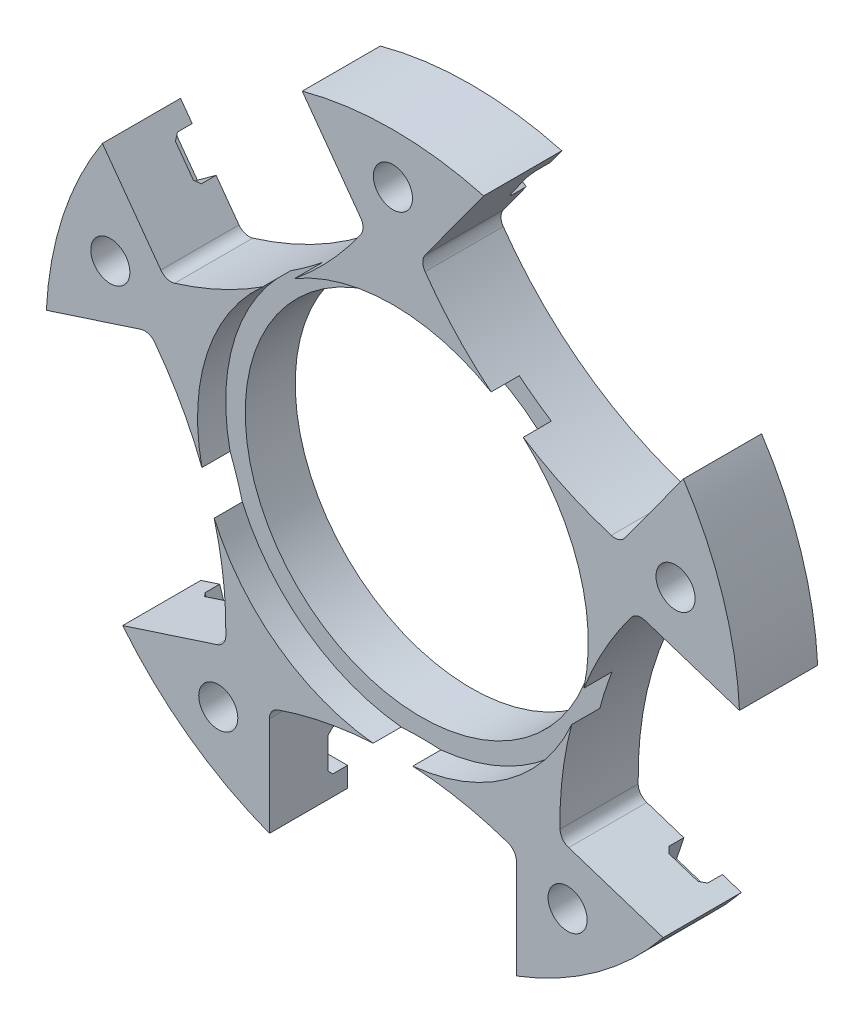
from build123d import *

# Parameters (mm, degrees)
SKETCH1_R                = 28.194
SKETCH1_R_2              = 14.2875
BOSS_EXTRUDE1_DEPTH      = 6.35
SKETCH1_3_R              = 15.875
SKETCH1_3_R_2            = 14.2875
CUT_EXTRUDE1_DEPTH       = 2.286
CUT_EXTRUDE5_DEPTH       = 41.374816062
CIRPATTERN1_COUNT        = 5
CUT_EXTRUDE6_DEPTH       = 1.8796
CIRPATTERN2_COUNT        = 5
CIRPATTERN2_COPY_1_DEPTH = 1.8796
CIRPATTERN2_COPY_2_DEPTH = 1.8796
CIRPATTERN2_COPY_3_DEPTH = 1.8796
CIRPATTERN2_COPY_4_DEPTH = 1.8796
SKETCH4_R                = 1.5875
CUT_EXTRUDE7_DEPTH       = 41.350542006
CIRPATTERN3_COUNT        = 5


with BuildPart() as part:
    # Sketch1 → Boss-Extrude1 (new body)
    with BuildSketch(Plane.XY):
        Circle(SKETCH1_R)
        Circle(SKETCH1_R_2, mode=Mode.SUBTRACT)
    extrude(amount=-BOSS_EXTRUDE1_DEPTH)

    # Sketch1_3 → Cut-Extrude1 (cut)
    with BuildSketch(Plane.XY):
        Circle(SKETCH1_3_R)
        Circle(SKETCH1_3_R_2, mode=Mode.SUBTRACT)
    extrude(amount=-CUT_EXTRUDE1_DEPTH, mode=Mode.SUBTRACT)

    # Sketch2 → Cut-Extrude5 (cut, through all)
    with BuildSketch(Plane.XY):
        with BuildLine():
            Line((-10.033, -28.194), (10.033, -28.194))
            Line((10.033, -28.194), (10.033, -18.273516145))
            ThreePointArc((10.033, -18.273516145), (9.84417878, -17.683574397), (9.347899083, -17.312911233))
            ThreePointArc((9.347899083, -17.312911233), (0, -15.748), (-9.347899083, -17.312911233))
            ThreePointArc((-9.347899083, -17.312911233), (-9.84417878, -17.683574397), (-10.033, -18.273516145))
            Line((-10.033, -18.273516145), (-10.033, -28.194))
        make_face()
    cut_extrude5 = extrude(amount=-CUT_EXTRUDE5_DEPTH, mode=Mode.SUBTRACT)

    # CirPattern1: Cut-Extrude5 ×5 about axis
    cirpattern1_axis = Axis((0, 0, 0), (0, 0, 1))
    for i in range(1, CIRPATTERN1_COUNT):
        add(cut_extrude5.rotate(cirpattern1_axis, i * 360 / CIRPATTERN1_COUNT), mode=Mode.SUBTRACT)

    # Sketch3 → Cut-Extrude6 (cut)
    with BuildSketch(Plane(origin=(-10.033, 0, 0), x_dir=(0, 0, -1), z_dir=(1, 0, 0))):
        Polygon((6.35, -21.433544869), (5.15112, -21.433544869), (4.7498, -21.834864869), (4.7498, -24.334224869), (5.15112, -24.735544869), (6.35, -24.735544869), align=None)
    cut_extrude6 = extrude(amount=-CUT_EXTRUDE6_DEPTH, mode=Mode.SUBTRACT)

    # Mirror1: Cut-Extrude6 across plane
    add(cut_extrude6.mirror(Plane(origin=(0, 0, 0), x_dir=(0, 0, 1), z_dir=(1, 0, 0))), mode=Mode.SUBTRACT)

    # CirPattern2: Cut-Extrude6 ×5 about axis
    cirpattern2_axis = Axis((0, 0, -6.35), (0, 0, 1))
    for i in range(1, CIRPATTERN2_COUNT):
        add(cut_extrude6.rotate(cirpattern2_axis, i * 360 / CIRPATTERN2_COUNT), mode=Mode.SUBTRACT)

    # CirPattern2 copy 1 sketch → CirPattern2 copy 1 (cut)
    with BuildSketch(Plane(origin=(3.100367505, 9.541950028, 0), x_dir=(0, 0, -1), z_dir=(-0.3090169943749473, -0.9510565162951535, 0))):
        Polygon((6.35, 21.433544869), (5.15112, 21.433544869), (4.7498, 21.834864869), (4.7498, 24.334224869), (5.15112, 24.735544869), (6.35, 24.735544869), align=None)
    extrude(amount=-CIRPATTERN2_COPY_1_DEPTH, mode=Mode.SUBTRACT)

    # CirPattern2 copy 2 sketch → CirPattern2 copy 2 (cut)
    with BuildSketch(Plane(origin=(-8.116867505, 5.897249436, 0), x_dir=(0, 0, -1), z_dir=(0.8090169943749475, -0.5877852522924731, 0))):
        Polygon((6.35, 21.433544869), (5.15112, 21.433544869), (4.7498, 21.834864869), (4.7498, 24.334224869), (5.15112, 24.735544869), (6.35, 24.735544869), align=None)
    extrude(amount=-CIRPATTERN2_COPY_2_DEPTH, mode=Mode.SUBTRACT)

    # CirPattern2 copy 3 sketch → CirPattern2 copy 3 (cut)
    with BuildSketch(Plane(origin=(-8.116867505, -5.897249436, 0), x_dir=(0, 0, -1), z_dir=(0.8090169943749475, 0.5877852522924731, 0))):
        Polygon((6.35, 21.433544869), (5.15112, 21.433544869), (4.7498, 21.834864869), (4.7498, 24.334224869), (5.15112, 24.735544869), (6.35, 24.735544869), align=None)
    extrude(amount=-CIRPATTERN2_COPY_3_DEPTH, mode=Mode.SUBTRACT)

    # CirPattern2 copy 4 sketch → CirPattern2 copy 4 (cut)
    with BuildSketch(Plane(origin=(3.100367505, -9.541950028, 0), x_dir=(0, 0, -1), z_dir=(-0.3090169943749474, 0.9510565162951536, 0))):
        Polygon((6.35, 21.433544869), (5.15112, 21.433544869), (4.7498, 21.834864869), (4.7498, 24.334224869), (5.15112, 24.735544869), (6.35, 24.735544869), align=None)
    extrude(amount=-CIRPATTERN2_COPY_4_DEPTH, mode=Mode.SUBTRACT)

    # Sketch4 → Cut-Extrude7 (cut, through all)
    with BuildSketch(Plane(origin=(0, 0, -6.35), x_dir=(-1, 0, 0), z_dir=(0, 0, -1))):
        with Locations((-14.191068427, -19.532330016)):
            Circle(SKETCH4_R)
    cut_extrude7 = extrude(amount=-CUT_EXTRUDE7_DEPTH, mode=Mode.SUBTRACT)

    # CirPattern3: Cut-Extrude7 ×5 about axis
    cirpattern3_axis = Axis((0, 0, -6.35), (0, 0, 1))
    for i in range(1, CIRPATTERN3_COUNT):
        add(cut_extrude7.rotate(cirpattern3_axis, i * 360 / CIRPATTERN3_COUNT), mode=Mode.SUBTRACT)


solid = part.part
